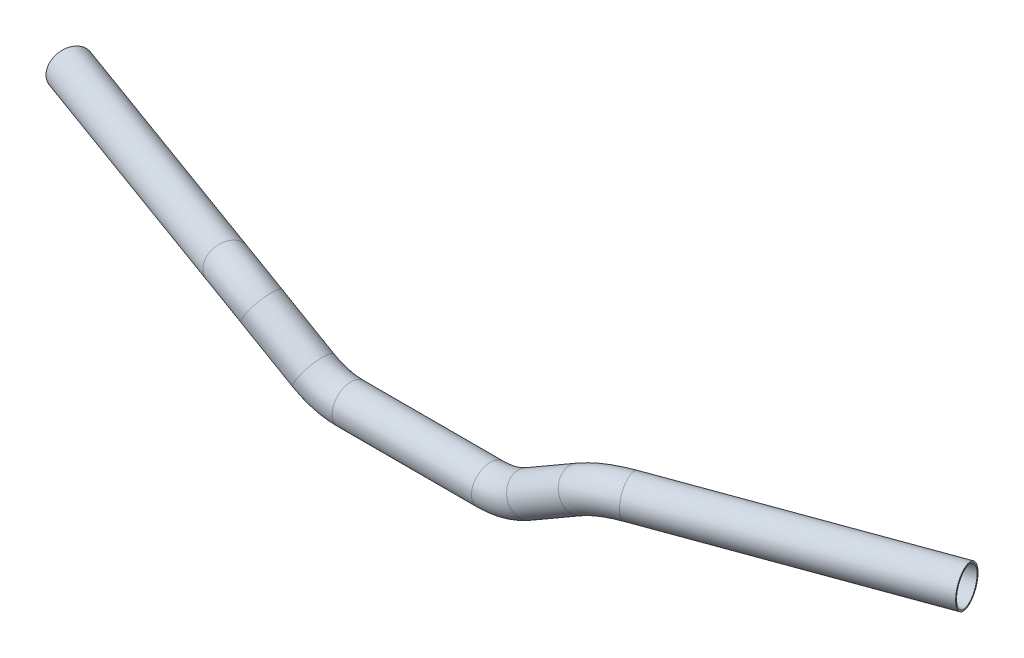
from build123d import *

# Parameters (mm, degrees)
ESQUISSE2_R   = 12.5
ESQUISSE2_R_2 = 11.5


with BuildPart() as part:
    # Balayage1: sweep along a curve in space
    with BuildLine() as balayage1_path:
        Line((-46.602540378, 0, 0), (0, 0, 0))
        ThreePointArc((-46.602540378, 0, 0), (-59.543492634, 1.703708686, 0), (-71.602540378, 6.698729811, 0))
        Line((-71.602540378, 6.698729811, 0), (-106.126093697, 26.630912613, 0))
        ThreePointArc((-106.126093697, 26.630912613, 0), (-120.302247758, 32.589576105, -1.403267638), (-135.054070374, 34.641016151, -5.479233521))
        Line((-135.054070374, 34.641016151, -5.479233521), (-299.933342618, 34.641016151, -65.490380865))
    # Esquisse2 → Balayage1 (sweep)
    with BuildSketch(Plane(origin=(0, 0, 0), x_dir=(0, 0, -1), z_dir=(1, 0, 0))):
        Circle(ESQUISSE2_R)
        Circle(ESQUISSE2_R_2, mode=Mode.SUBTRACT)
    balayage1 = sweep(path=balayage1_path.line)

    # Symétrie1: Balayage1 across plane
    add(balayage1.mirror(Plane(origin=(0, 0, 0), x_dir=(0, 0, 1), z_dir=(1, 0, 0))))


solid = part.part
